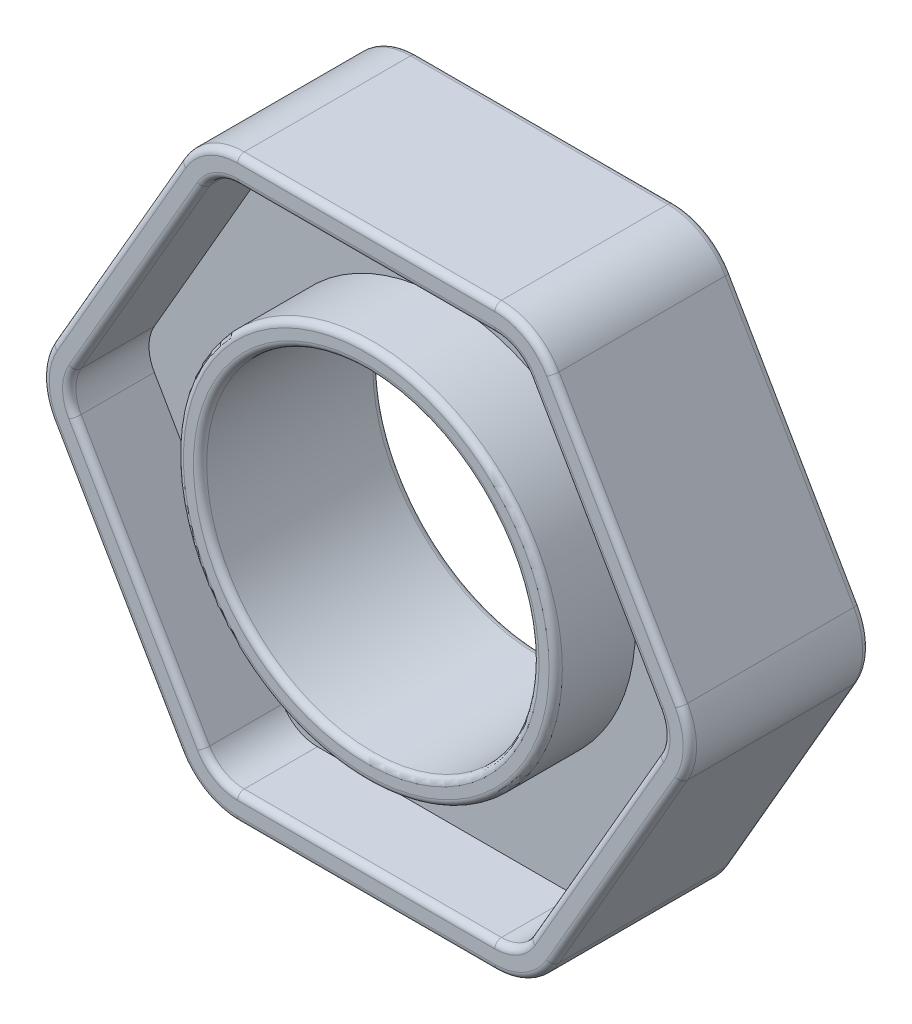
from build123d import *

# Parameters (mm, degrees)
EXTRUDE_1_DEPTH     = 13.5
CUT_EXTRUDE_1_DEPTH = 6
CUT_EXTRUDE_2_DEPTH = 6
EXTRUDE_START       = -7.5
SKETCH_4_R          = 14.25
EXTRUDE_2_DEPTH     = 13.5
CUT_EXTRUDE_3_REACH = 15.5
SKETCH_5_R          = 12.5
FILLET_1_R          = 0.5


with BuildPart() as part:
    # 草圖1 → 填料-伸長1 (new body)
    with BuildSketch(Plane.XY):
        with BuildLine():
            Line((23.671361037, 2.5), (14.000744028, 19.25))
            ThreePointArc((14.000744028, 19.25), (12.170617009, 21.080127019), (9.670617009, 21.75))
            Line((9.670617009, 21.75), (-9.670617009, 21.75))
            ThreePointArc((-9.670617009, 21.75), (-12.170617009, 21.080127019), (-14.000744028, 19.25))
            Line((-14.000744028, 19.25), (-23.671361037, 2.5))
            ThreePointArc((-23.671361037, 2.5), (-24.341234018, 0), (-23.671361037, -2.5))
            Line((-23.671361037, -2.5), (-14.000744028, -19.25))
            ThreePointArc((-14.000744028, -19.25), (-12.170617009, -21.080127019), (-9.670617009, -21.75))
            Line((-9.670617009, -21.75), (9.670617009, -21.75))
            ThreePointArc((9.670617009, -21.75), (12.170617009, -21.080127019), (14.000744028, -19.25))
            Line((14.000744028, -19.25), (23.671361037, -2.5))
            ThreePointArc((23.671361037, -2.5), (24.341234018, 0), (23.671361037, 2.5))
        make_face()
    extrude(amount=EXTRUDE_1_DEPTH)

    # 草圖2 → 除料-伸長1 (cut)
    with BuildSketch(Plane.XY.offset(13.5)):
        with BuildLine():
            Line((9.670617009, 19.75), (-9.670617009, 19.75))
            ThreePointArc((-9.670617009, 19.75), (-11.170617009, 19.348076211), (-12.26869322, 18.25))
            Line((-12.26869322, 18.25), (-21.939310229, 1.5))
            ThreePointArc((-21.939310229, 1.5), (-22.341234018, 0), (-21.939310229, -1.5))
            Line((-21.939310229, -1.5), (-12.26869322, -18.25))
            ThreePointArc((-12.26869322, -18.25), (-11.170617009, -19.348076211), (-9.670617009, -19.75))
            Line((-9.670617009, -19.75), (9.670617009, -19.75))
            ThreePointArc((9.670617009, -19.75), (11.170617009, -19.348076211), (12.26869322, -18.25))
            Line((12.26869322, -18.25), (21.939310229, -1.5))
            ThreePointArc((21.939310229, -1.5), (22.341234018, 0), (21.939310229, 1.5))
            Line((21.939310229, 1.5), (12.26869322, 18.25))
            ThreePointArc((12.26869322, 18.25), (11.170617009, 19.348076211), (9.670617009, 19.75))
        make_face()
    extrude(amount=-CUT_EXTRUDE_1_DEPTH, mode=Mode.SUBTRACT)

    # 草圖3 → 除料-伸長2 (cut)
    with BuildSketch(Plane(origin=(0, 0, 0), x_dir=(-1, 0, 0), z_dir=(0, 0, -1))):
        with BuildLine():
            Line((-12.26869322, 18.25), (-21.939310229, 1.5))
            ThreePointArc((-21.939310229, 1.5), (-22.341234018, 0), (-21.939310229, -1.5))
            Line((-21.939310229, -1.5), (-12.26869322, -18.25))
            ThreePointArc((-12.26869322, -18.25), (-11.170617009, -19.348076211), (-9.670617009, -19.75))
            Line((-9.670617009, -19.75), (9.670617009, -19.75))
            ThreePointArc((9.670617009, -19.75), (11.170617009, -19.348076211), (12.26869322, -18.25))
            Line((12.26869322, -18.25), (21.939310229, -1.5))
            ThreePointArc((21.939310229, -1.5), (22.341234018, 0), (21.939310229, 1.5))
            Line((21.939310229, 1.5), (12.26869322, 18.25))
            ThreePointArc((12.26869322, 18.25), (11.170617009, 19.348076211), (9.670617009, 19.75))
            Line((9.670617009, 19.75), (-9.670617009, 19.75))
            ThreePointArc((-9.670617009, 19.75), (-11.170617009, 19.348076211), (-12.26869322, 18.25))
        make_face()
    extrude(amount=-CUT_EXTRUDE_2_DEPTH, mode=Mode.SUBTRACT)

    # 草圖4 → 填料-伸長2 (add)
    with BuildSketch(Plane(origin=(0, 0, 6), x_dir=(-1, 0, 0), z_dir=(0, 0, -1)).offset(EXTRUDE_START)):
        Circle(SKETCH_4_R)
    extrude(amount=EXTRUDE_2_DEPTH)

    # 草圖5 → 除料-伸長3 (cut, up to next)
    with BuildSketch(Plane.XY.offset(13.5), mode=Mode.PRIVATE) as cut_extrude_3_sk1:
        Circle(SKETCH_5_R)
    cut_extrude_3_tool1 = extrude(cut_extrude_3_sk1.sketch, amount=-CUT_EXTRUDE_3_REACH, mode=Mode.PRIVATE) & part.part
    add(cut_extrude_3_tool1.solids().sort_by_distance((0, 0, 13.5))[0], mode=Mode.SUBTRACT)

    # 圓角1
    fillet_1_edges = [part.edges().sort_by_distance(p)[0] for p in [
        (14.25, 0, 13.5),
        (14.25, 0, 0),
        (-12.5, 0, 13.5),
        (-12.5, 0, 0),
        (18.836052532, 10.875, 0),
        (24.341234018, 0, 0),
        (-12.170617009, 21.080127019, 13.5),
        (18.836052532, -10.875, 0),
        (12.170617009, -21.080127019, 0),
        (0, -21.75, 0),
        (-12.170617009, -21.080127019, 0),
        (-18.836052532, -10.875, 0),
        (-24.341234018, 0, 0),
        (-18.836052532, 10.875, 0),
        (-12.170617009, 21.080127019, 0),
        (0, 21.75, 0),
        (12.170617009, 21.080127019, 0),
        (-18.836052532, 10.875, 13.5),
        (-24.341234018, 0, 13.5),
        (-18.836052532, -10.875, 13.5),
        (-12.170617009, -21.080127019, 13.5),
        (0, -21.75, 13.5),
        (12.170617009, -21.080127019, 13.5),
        (18.836052532, -10.875, 13.5),
        (24.341234018, 0, 13.5),
        (11.170617009, 19.348076211, 13.5),
        (0, 19.75, 13.5),
        (-11.170617009, 19.348076211, 13.5),
        (-17.104001725, 9.875, 13.5),
        (-22.341234018, 0, 13.5),
        (-17.104001725, -9.875, 13.5),
        (-11.170617009, -19.348076211, 13.5),
        (0, -19.75, 13.5),
        (11.170617009, -19.348076211, 13.5),
        (17.104001725, -9.875, 13.5),
        (22.341234018, 0, 13.5),
        (18.836052532, 10.875, 13.5),
        (17.104001725, 9.875, 13.5),
        (12.170617009, 21.080127019, 13.5),
        (11.170617009, 19.348076211, 0),
        (17.104001725, 9.875, 0),
        (22.341234018, 0, 0),
        (17.104001725, -9.875, 0),
        (11.170617009, -19.348076211, 0),
        (0, -19.75, 0),
        (-11.170617009, -19.348076211, 0),
        (-17.104001725, -9.875, 0),
        (-22.341234018, 0, 0),
        (-17.104001725, 9.875, 0),
        (-11.170617009, 19.348076211, 0),
        (0, 19.75, 0),
        (0, 21.75, 13.5),
    ]]
    fillet(fillet_1_edges, radius=FILLET_1_R)


solid = part.part
